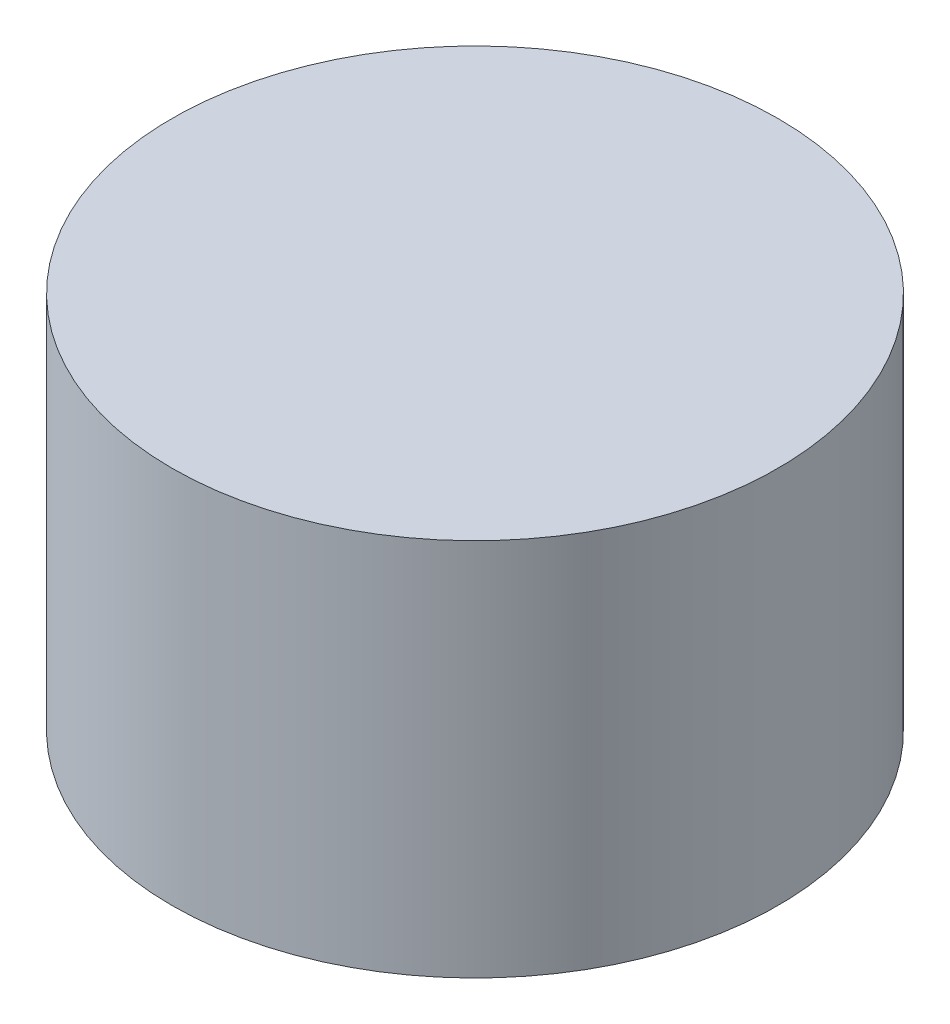
from build123d import *

# Parameters (mm, degrees)
SKETCH1_R           = 6.35
BOSS_EXTRUDE1_DEPTH = 7.9375


with BuildPart() as part:
    # Sketch1 → Boss-Extrude1 (new body)
    with BuildSketch(Plane(origin=(0, 0, 0), x_dir=(1, 0, 0), z_dir=(0, 1, 0))):
        Circle(SKETCH1_R)
    extrude(amount=BOSS_EXTRUDE1_DEPTH)


solid = part.part
